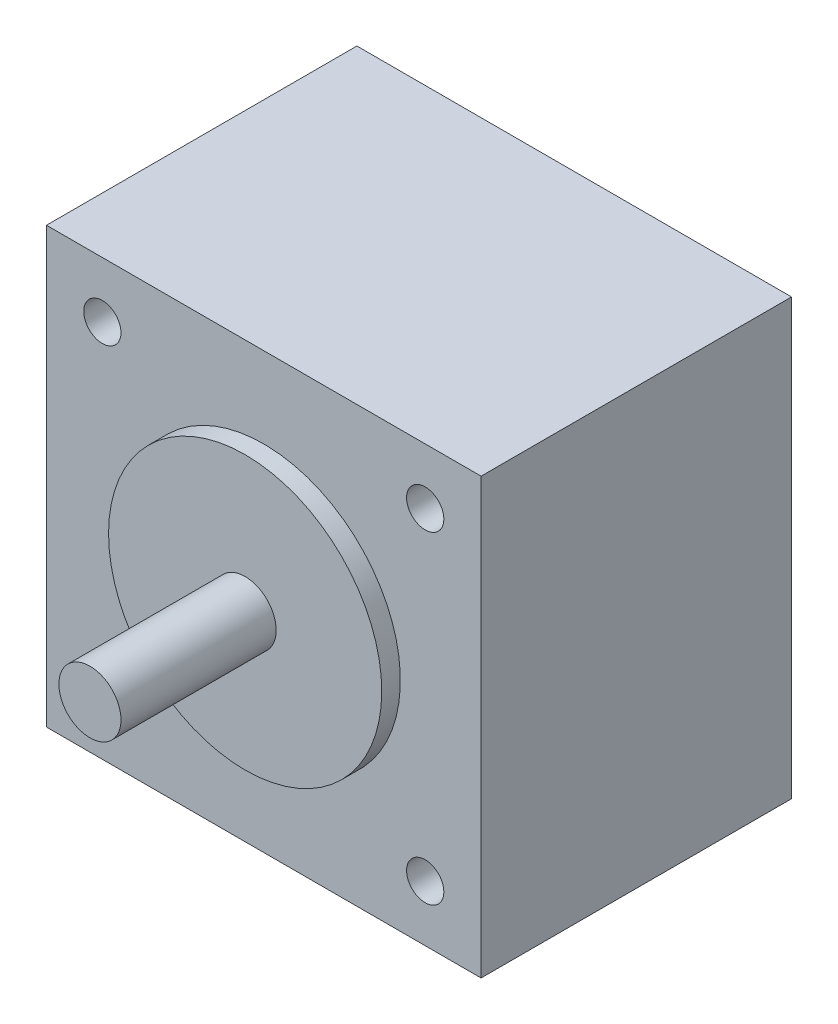
from build123d import *

# Parameters (mm, degrees)
SKETCH1_W           = 35
SKETCH1_H           = 35
SKETCH1_R           = 1.5
BOSS_EXTRUDE1_DEPTH = 25
SKETCH2_R           = 11
BOSS_EXTRUDE2_DEPTH = 1.5
SKETCH3_R           = 2.5
BOSS_EXTRUDE3_DEPTH = 12.5
SKETCH4_R           = 2.5
BOSS_EXTRUDE4_DEPTH = 10


with BuildPart() as part:
    # Sketch1 → Boss-Extrude1 (new body)
    with BuildSketch(Plane.XY):
        Rectangle(SKETCH1_W, SKETCH1_H)
        with Locations((-13, 13)):
            Circle(SKETCH1_R, mode=Mode.SUBTRACT)
        with Locations((13, 13)):
            Circle(SKETCH1_R, mode=Mode.SUBTRACT)
        with Locations((-13, -13)):
            Circle(SKETCH1_R, mode=Mode.SUBTRACT)
        with Locations((13, -13)):
            Circle(SKETCH1_R, mode=Mode.SUBTRACT)
    extrude(amount=BOSS_EXTRUDE1_DEPTH)

    # Sketch2 → Boss-Extrude2 (add)
    with BuildSketch(Plane.XY.offset(25)):
        Circle(SKETCH2_R)
    extrude(amount=BOSS_EXTRUDE2_DEPTH)

    # Sketch3 → Boss-Extrude3 (add)
    with BuildSketch(Plane.XY.offset(26.5)):
        Circle(SKETCH3_R)
    extrude(amount=BOSS_EXTRUDE3_DEPTH)

    # Sketch4 → Boss-Extrude4 (add)
    with BuildSketch(Plane(origin=(0, 0, 0), x_dir=(-1, 0, 0), z_dir=(0, 0, -1))):
        Circle(SKETCH4_R)
    extrude(amount=BOSS_EXTRUDE4_DEPTH)


solid = part.part
